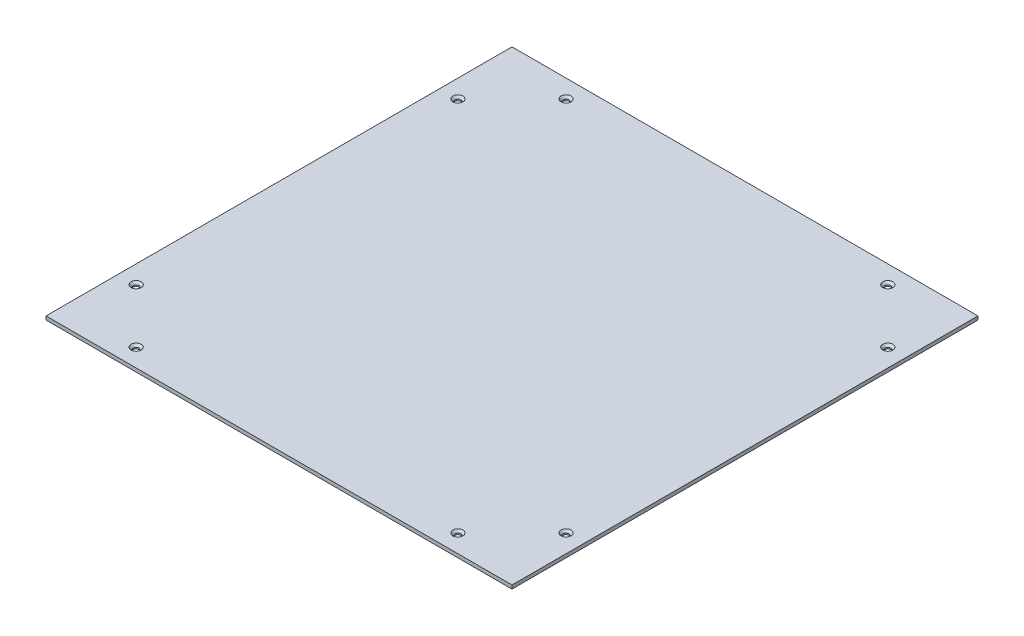
from build123d import *

# Parameters (mm, degrees)
SKETCH1_W           = 646
SKETCH1_H           = 646
BOSS_EXTRUDE1_DEPTH = 5
SKETCH2_R           = 4
CUT_EXTRUDE1_DEPTH  = 6
CHAMFER1_SIZE       = 3


with BuildPart() as part:
    # Sketch1 → Boss-Extrude1 (new body)
    with BuildSketch(Plane(origin=(0, 0, 0), x_dir=(1, 0, 0), z_dir=(0, 1, 0))):
        Rectangle(SKETCH1_W, SKETCH1_H)
    extrude(amount=BOSS_EXTRUDE1_DEPTH)

    # Sketch2 → Cut-Extrude1 (cut, through all)
    with BuildSketch(Plane(origin=(0, 5, 0), x_dir=(1, 0, 0), z_dir=(0, 1, 0))):
        with Locations((-223, -298)):
            Circle(SKETCH2_R)
        with Locations((223, -298)):
            Circle(SKETCH2_R)
        with Locations((-298, -223)):
            Circle(SKETCH2_R)
        with Locations((298, -223)):
            Circle(SKETCH2_R)
        with Locations((298, 223)):
            Circle(SKETCH2_R)
        with Locations((223, 298)):
            Circle(SKETCH2_R)
        with Locations((-223, 298)):
            Circle(SKETCH2_R)
        with Locations((-298, 223)):
            Circle(SKETCH2_R)
    extrude(amount=-CUT_EXTRUDE1_DEPTH, mode=Mode.SUBTRACT)

    # Chamfer1
    chamfer1_edges = [part.edges().sort_by_distance(p)[0] for p in [
        (-227, 5, 298),
        (219, 5, 298),
        (-302, 5, 223),
        (294, 5, 223),
        (294, 5, -223),
        (219, 5, -298),
        (-227, 5, -298),
        (-302, 5, -223),
    ]]
    chamfer(chamfer1_edges, length=CHAMFER1_SIZE)


solid = part.part
